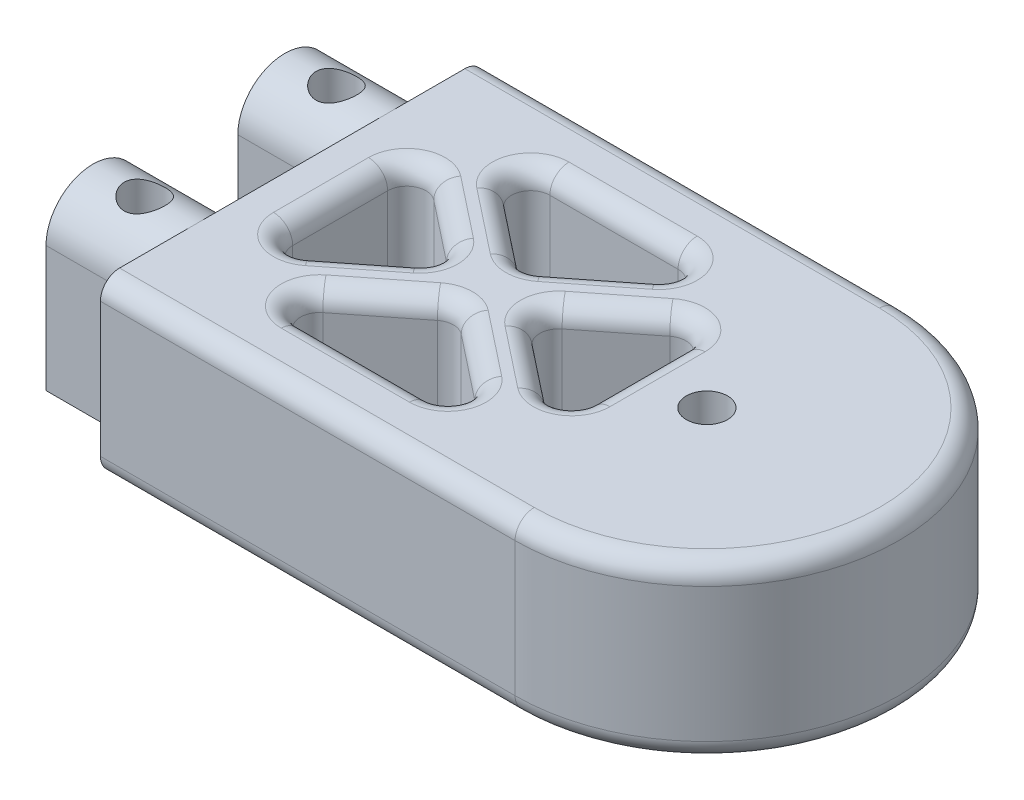
from build123d import *

# Parameters (mm, degrees)
SKETCH1_W           = 40
SKETCH1_H           = 18
BOSS_EXTRUDE1_DEPTH = 63.235
CUT_EXTRUDE1_DEPTH  = 19
SKETCH3_R           = 2.15
CUT_EXTRUDE2_DEPTH  = 19
FILLET1_R           = 2
BOSS_EXTRUDE2_DEPTH = 10.77
SKETCH5_R           = 2.125
CUT_EXTRUDE3_DEPTH  = 19
CUT_EXTRUDE4_DEPTH  = 19.0000001
FILLET3_R           = 2


with BuildPart() as part:
    # Sketch1 → Boss-Extrude1 (new body)
    with BuildSketch(Plane(origin=(0, 0, 0), x_dir=(0, 0, -1), z_dir=(1, 0, 0))):
        Rectangle(SKETCH1_W, SKETCH1_H)
    extrude(amount=BOSS_EXTRUDE1_DEPTH)

    # Sketch2 → Cut-Extrude1 (cut, through all)
    with BuildSketch(Plane(origin=(0, 9, 0), x_dir=(1, 0, 0), z_dir=(0, 1, 0))):
        with BuildLine():
            Line((43.235, -20), (63.235, -20))
            Line((63.235, -20), (63.235, 0))
            ThreePointArc((63.235, 0), (57.377135624, -14.142135624), (43.235, -20))
        make_face()
    cut_extrude1 = extrude(amount=-CUT_EXTRUDE1_DEPTH, mode=Mode.SUBTRACT)

    # Mirror1: Cut-Extrude1 across plane
    add(cut_extrude1.mirror(Plane(origin=(0, 0, 0), x_dir=(1, 0, 0), z_dir=(0, 0, -1))), mode=Mode.SUBTRACT)

    # Sketch3 → Cut-Extrude2 (cut, through all)
    with BuildSketch(Plane(origin=(0, 9, 0), x_dir=(1, 0, 0), z_dir=(0, 1, 0))):
        with Locations((43.235, 0)):
            Circle(SKETCH3_R)
    extrude(amount=-CUT_EXTRUDE2_DEPTH, mode=Mode.SUBTRACT)

    # Fillet1
    fillet1_edges = [part.edges().sort_by_distance(p)[0] for p in [
        (21.6175, -9, 20),
        (21.6175, 9, 20),
        (63.235, -9, 0),
        (63.235, 9, 0),
        (21.6175, -9, -20),
        (21.6175, 9, -20),
    ]]
    fillet(fillet1_edges, radius=FILLET1_R)

    # Sketch4 → Boss-Extrude2 (add)
    with BuildSketch(Plane.ZY):
        with BuildLine():
            Line((14.9, -9), (5.1, -9))
            Line((5.1, -9), (5.1, 4.1))
            ThreePointArc((5.1, 4.1), (10, 9), (14.9, 4.1))
            Line((14.9, 4.1), (14.9, -9))
        make_face()
        with BuildLine():
            Line((-14.9, -9), (-5.1, -9))
            Line((-5.1, -9), (-5.1, 4.1))
            ThreePointArc((-5.1, 4.1), (-10, 9), (-14.9, 4.1))
            Line((-14.9, 4.1), (-14.9, -9))
        make_face()
    extrude(amount=BOSS_EXTRUDE2_DEPTH)

    # Sketch5 → Cut-Extrude3 (cut, through all)
    with BuildSketch(Plane.XZ.offset(9)):
        with Locations((-5.385, 10)):
            Circle(SKETCH5_R)
        with Locations((-5.385, -10)):
            Circle(SKETCH5_R)
    extrude(amount=-CUT_EXTRUDE3_DEPTH, mode=Mode.SUBTRACT)

    # Sketch6 → Cut-Extrude4 (cut, through all)
    with BuildSketch(Plane(origin=(0, 9, 0), x_dir=(1, 0, 0), z_dir=(0, 1, 0))):
        Polygon((8.096295962, 13), (32.988704038, 13), (20.5425, 3.183956383), align=None)
        Polygon((36.085, 9.074066823), (36.085, -9.074066823), (24.579581775, 0), align=None)
        Polygon((32.988704038, -13), (8.096295962, -13), (20.5425, -3.183956383), align=None)
        Polygon((5, 9.074066823), (5, -9.074066823), (16.505418225, 0), align=None)
    extrude(amount=-CUT_EXTRUDE4_DEPTH, mode=Mode.SUBTRACT)

    # Fillet3
    fillet3_edges = [part.edges().sort_by_distance(p)[0] for p in [
        (26.765602019, -9, 8.091978192),
        (20.5425, 0, 3.183956383),
        (20.5425, -9, 13),
        (32.988704038, 0, 13),
        (14.319397981, -9, 8.091978192),
        (8.096295962, 0, 13),
        (26.765602019, 9, 8.091978192),
        (14.319397981, 9, 8.091978192),
        (20.5425, 9, 13),
        (14.319397981, -9, -8.091978192),
        (20.5425, 0, -3.183956383),
        (20.5425, -9, -13),
        (8.096295962, 0, -13),
        (26.765602019, -9, -8.091978192),
        (32.988704038, 0, -13),
        (14.319397981, 9, -8.091978192),
        (26.765602019, 9, -8.091978192),
        (20.5425, 9, -13),
        (30.332290888, -9, 4.537033411),
        (36.085, 0, 9.074066823),
        (30.332290888, -9, -4.537033411),
        (24.579581775, 0, 0),
        (36.085, -9, 0),
        (36.085, 0, -9.074066823),
        (30.332290888, 9, 4.537033411),
        (36.085, 9, 0),
        (30.332290888, 9, -4.537033411),
        (10.752709112, -9, -4.537033411),
        (5, 0, -9.074066823),
        (10.752709112, -9, 4.537033411),
        (16.505418225, 0, 0),
        (5, -9, 0),
        (5, 0, 9.074066823),
        (10.752709112, 9, -4.537033411),
        (5, 9, 0),
        (10.752709112, 9, 4.537033411),
    ]]
    fillet(fillet3_edges, radius=FILLET3_R)


solid = part.part
